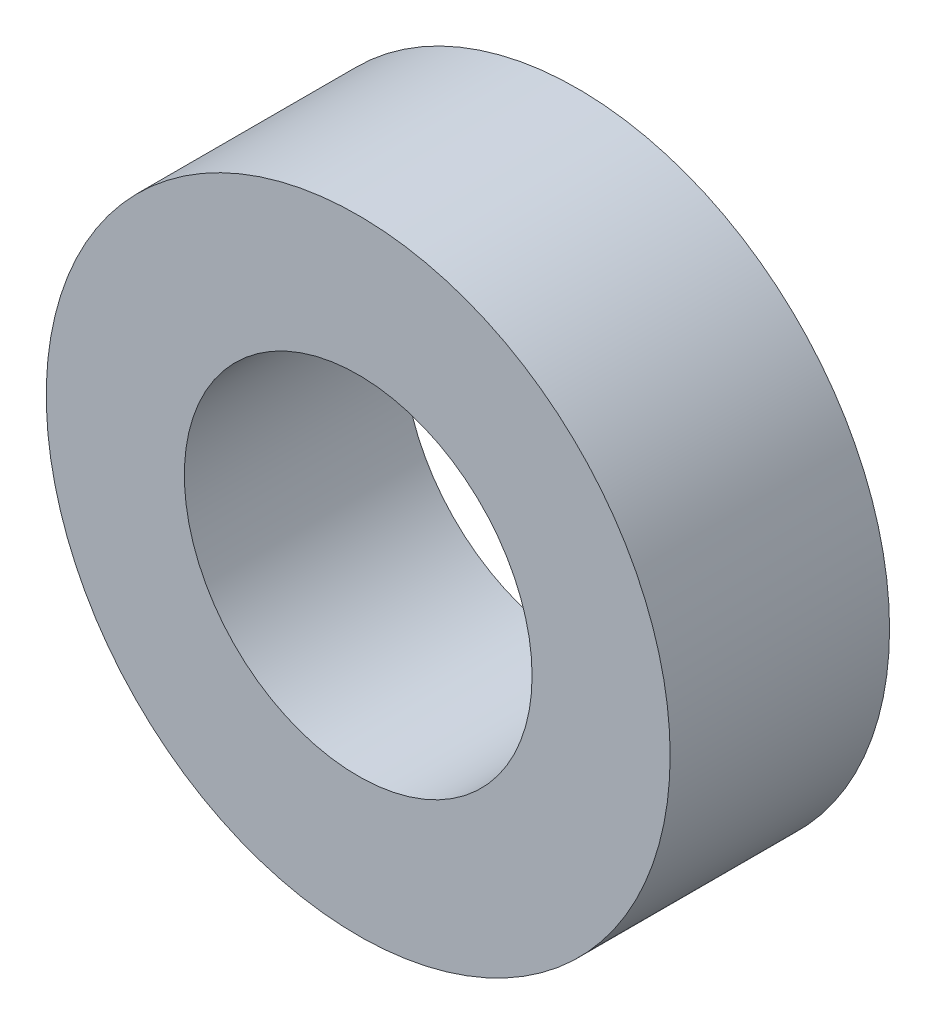
from build123d import *

# Parameters (mm, degrees)
SKETCH1_R           = 72.23125
SKETCH1_R_2         = 40.259
BOSS_EXTRUDE1_DEPTH = 50.8


with BuildPart() as part:
    # Sketch1 → Boss-Extrude1 (new body)
    with BuildSketch(Plane.XY):
        Circle(SKETCH1_R)
        Circle(SKETCH1_R_2, mode=Mode.SUBTRACT)
    extrude(amount=BOSS_EXTRUDE1_DEPTH)


solid = part.part
